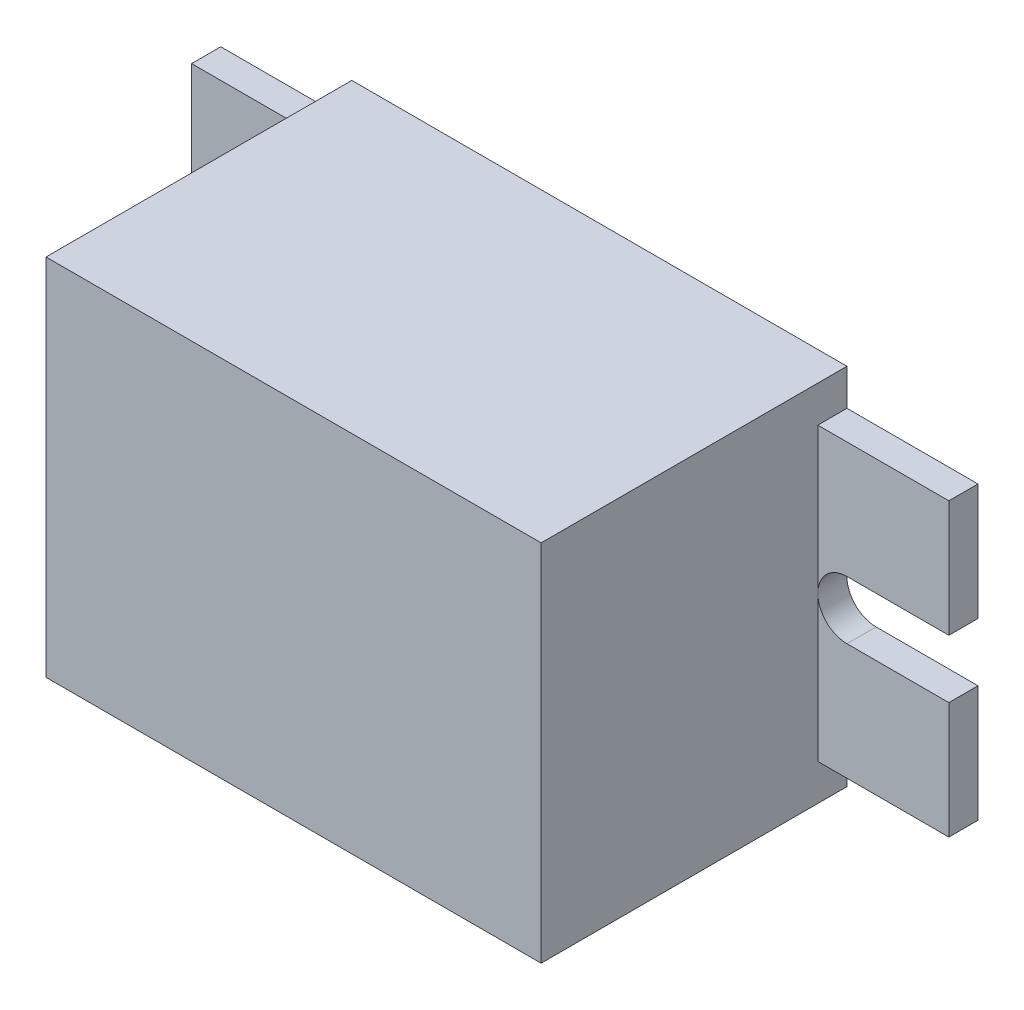
from build123d import *

# Parameters (mm, degrees)
SKETCH1_W           = 34
SKETCH1_H           = 25
BOSS_EXTRUDE1_DEPTH = 21
BOSS_EXTRUDE2_DEPTH = 2


with BuildPart() as part:
    # Sketch1 → Boss-Extrude1 (new body)
    with BuildSketch(Plane.XY):
        with Locations((17, 12.5)):
            Rectangle(SKETCH1_W, SKETCH1_H)
    extrude(amount=BOSS_EXTRUDE1_DEPTH)

    # Sketch3 → Boss-Extrude2 (add)
    with BuildSketch(Plane.XY):
        with BuildLine():
            Line((0, 12.5), (0, 22.5))
            Line((0, 22.5), (-9, 22.5))
            Line((-9, 22.5), (-9, 14.5))
            Line((-9, 14.5), (-2, 14.5))
            ThreePointArc((-2, 14.5), (-0.585786438, 13.914213562), (0, 12.5))
        make_face()
        with BuildLine():
            Line((0, 2.5), (0, 12.5))
            ThreePointArc((0, 12.5), (-0.585786438, 11.085786438), (-2, 10.5))
            Line((-2, 10.5), (-9, 10.5))
            Line((-9, 10.5), (-9, 2.5))
            Line((-9, 2.5), (0, 2.5))
        make_face()
        with BuildLine():
            ThreePointArc((36, 10.5), (34.585786455, 11.08578642), (34, 12.499999949))
            Line((34, 12.499999949), (34, 2.5))
            Line((34, 2.5), (43, 2.5))
            Line((43, 2.5), (43, 10.5))
            Line((43, 10.5), (36, 10.5))
        make_face()
        with BuildLine():
            Line((43, 22.5), (34, 22.5))
            Line((34, 22.5), (34, 12.499999949))
            ThreePointArc((34, 12.499999949), (34.58578642, 13.914213545), (36, 14.5))
            Line((36, 14.5), (43, 14.5))
            Line((43, 14.5), (43, 22.5))
        make_face()
    extrude(amount=BOSS_EXTRUDE2_DEPTH)


solid = part.part
